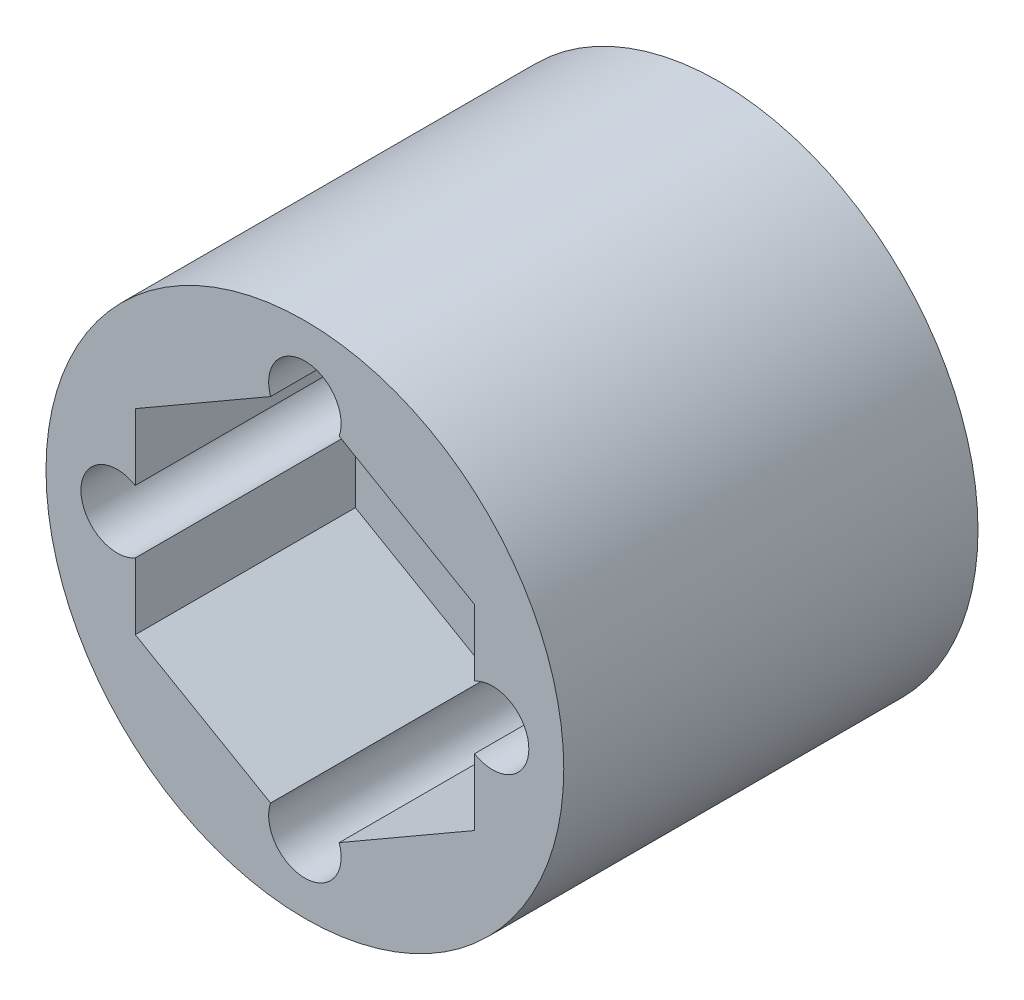
from build123d import *

# Parameters (mm, degrees)
SKETCH1_R           = 10
SKETCH1_R_2         = 1.4
SKETCH1_R_3         = 4.25
BOSS_EXTRUDE1_DEPTH = 16
CUT_EXTRUDE1_DEPTH  = 8.5


with BuildPart() as part:
    # Sketch1 → Boss-Extrude1 (new body)
    with BuildSketch(Plane.XY):
        Circle(SKETCH1_R)
        with Locations((0, 7.25)):
            Circle(SKETCH1_R_2, mode=Mode.SUBTRACT)
        Circle(SKETCH1_R_3, mode=Mode.SUBTRACT)
        with Locations((7.25, 0)):
            Circle(SKETCH1_R_2, mode=Mode.SUBTRACT)
        with Locations((0, -7.25)):
            Circle(SKETCH1_R_2, mode=Mode.SUBTRACT)
        with Locations((-7.25, 0)):
            Circle(SKETCH1_R_2, mode=Mode.SUBTRACT)
    extrude(amount=BOSS_EXTRUDE1_DEPTH)

    # Sketch2 → Cut-Extrude1 (cut)
    with BuildSketch(Plane.XY.offset(16)):
        Polygon((0, 7.563288526), (-6.55, 3.781644263), (-6.55, -3.781644263), (0, -7.563288526), (6.55, -3.781644263), (6.55, 3.781644263), align=None)
    extrude(amount=-CUT_EXTRUDE1_DEPTH, mode=Mode.SUBTRACT)


solid = part.part
